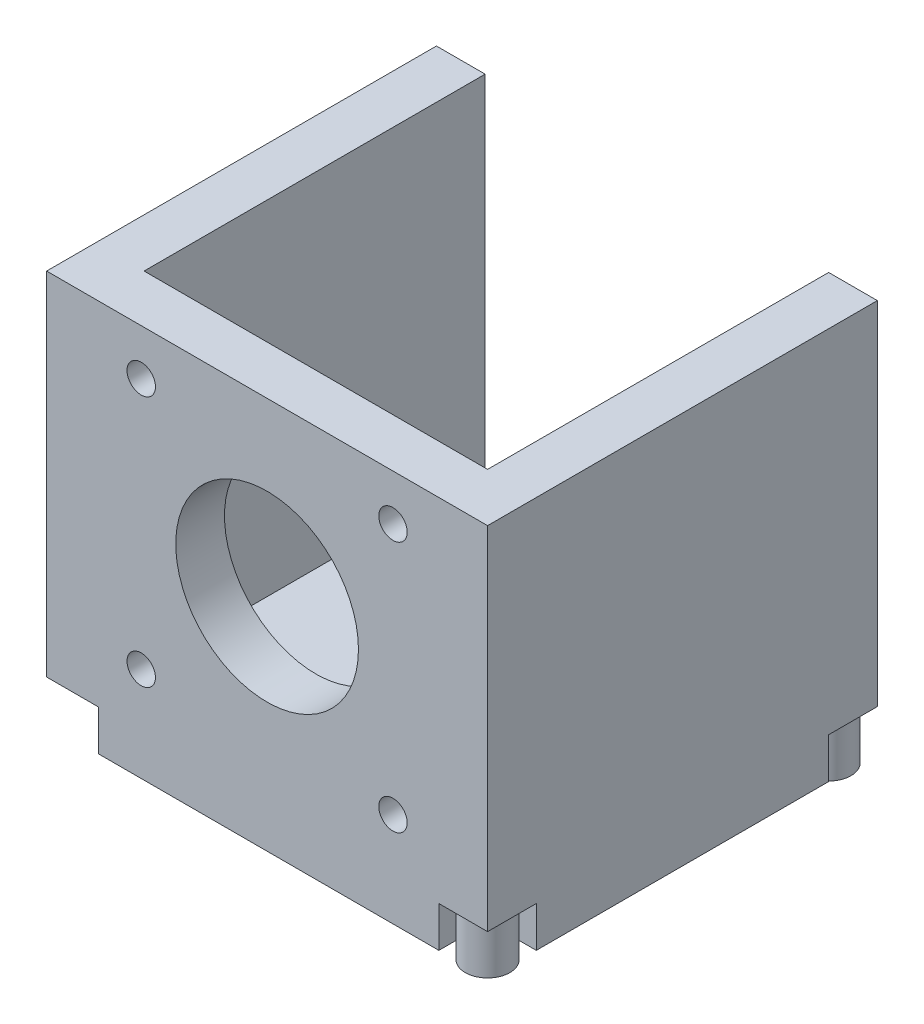
from build123d import *

# Parameters (mm, degrees)
SKETCH_1_W          = 42.3
SKETCH_1_H          = 42.3
SKETCH_1_R          = 1.75
SKETCH_1_R_2        = 11.25
EXTRUDE_1_DEPTH     = 6
SKETCH_2_W          = 48
SKETCH_2_H          = 42.3
EXTRUDE_2_DEPTH     = 6
SKETCH_3_W          = 48
SKETCH_3_H          = 42.3
EXTRUDE_3_DEPTH     = 6
SKETCH_4_W          = 54.3
SKETCH_4_H          = 48
EXTRUDE_4_DEPTH     = 6
SKETCH_5_W          = 6
SKETCH_5_H          = 6
SKETCH_5_W_2        = 6.359997754
CUT_EXTRUDE_1_DEPTH = 5
SKETCH_6_R          = 2.75
EXTRUDE_5_DEPTH     = 6
SKETCH_7_R          = 2.75
EXTRUDE_6_DEPTH     = 6


with BuildPart() as part:
    # Эскиз1 → Бобышка-Вытянуть1 (new body)
    with BuildSketch(Plane.XY):
        with Locations((21.15, 21.15)):
            Rectangle(SKETCH_1_W, SKETCH_1_H)
        with Locations((36.65, 36.65)):
            Circle(SKETCH_1_R, mode=Mode.SUBTRACT)
        with Locations((5.65, 36.65)):
            Circle(SKETCH_1_R, mode=Mode.SUBTRACT)
        with Locations((5.65, 5.65)):
            Circle(SKETCH_1_R, mode=Mode.SUBTRACT)
        with Locations((36.65, 5.65)):
            Circle(SKETCH_1_R, mode=Mode.SUBTRACT)
        with Locations((21.15, 21.15)):
            Circle(SKETCH_1_R_2, mode=Mode.SUBTRACT)
    extrude(amount=EXTRUDE_1_DEPTH)

    # Эскиз2 → Бобышка-Вытянуть2 (add)
    with BuildSketch(Plane.ZY):
        with Locations((-18, 21.15)):
            Rectangle(SKETCH_2_W, SKETCH_2_H)
    extrude(amount=EXTRUDE_2_DEPTH)

    # Эскиз3 → Бобышка-Вытянуть3 (add)
    with BuildSketch(Plane(origin=(42.3, 0, 0), x_dir=(0, 0, -1), z_dir=(1, 0, 0))):
        with Locations((18, 21.15)):
            Rectangle(SKETCH_3_W, SKETCH_3_H)
    extrude(amount=EXTRUDE_3_DEPTH)

    # Эскиз4 → Бобышка-Вытянуть4 (add)
    with BuildSketch(Plane.XZ):
        with Locations((21.15, -18)):
            Rectangle(SKETCH_4_W, SKETCH_4_H)
    extrude(amount=EXTRUDE_4_DEPTH)

    # Эскиз5 → Вырез-Вытянуть1 (cut)
    with BuildSketch(Plane.XZ.offset(6)):
        with Locations((45.3, -39)):
            Rectangle(SKETCH_5_W, SKETCH_5_H)
        with Locations((-3, -39)):
            Rectangle(SKETCH_5_W, SKETCH_5_H)
        with Locations((-2.820001123, 3)):
            Rectangle(SKETCH_5_W_2, SKETCH_5_H)
        with Locations((45.3, 3)):
            Rectangle(SKETCH_5_W, SKETCH_5_H)
    extrude(amount=-CUT_EXTRUDE_1_DEPTH, mode=Mode.SUBTRACT)

    # Эскиз6 → Бобышка-Вытянуть5 (add)
    with BuildSketch(Plane.XZ.offset(1)):
        with Locations((45.3, 3)):
            Circle(SKETCH_6_R)
    extrude(amount=EXTRUDE_5_DEPTH)

    # Эскиз7 → Бобышка-Вытянуть6 (add)
    with BuildSketch(Plane.XZ.offset(1)):
        with Locations((45.3, -39)):
            Circle(SKETCH_7_R)
    extrude(amount=EXTRUDE_6_DEPTH)


solid = part.part
